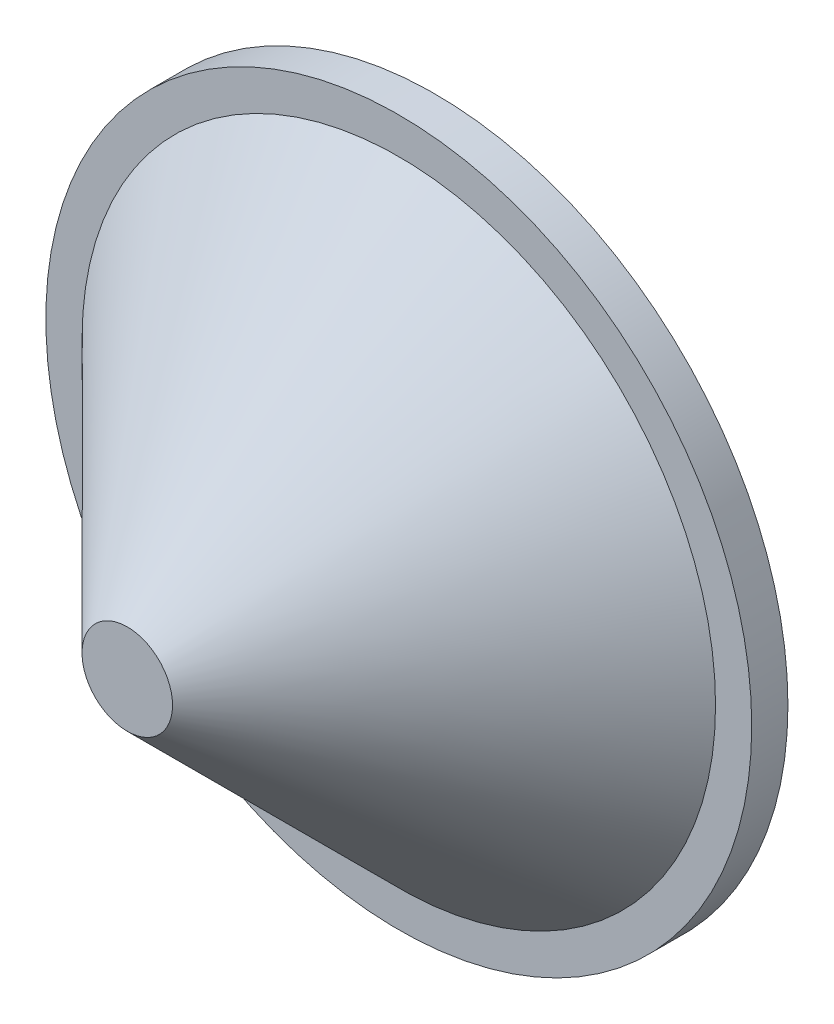
from build123d import *

# Parameters (mm, degrees)
EXTRUDE_1_DEPTH = 5


with BuildPart() as part:
    # Эскиз1 → Повернуть1 (revolve)
    with BuildSketch(Plane(origin=(0, 0, 0), x_dir=(0, 0, -1), z_dir=(1, 0, 0))):
        Polygon((0, 0), (0, 39), (-4, 39), (-4, 35), (-34, 5), (-34, 0), align=None)
    revolve(axis=Axis((0, 0, 926.802095793), (0, 0, -1)))

    # Эскиз2 → Бобышка-Вытянуть1 (add)
    with BuildSketch(Plane(origin=(0, 0, 0), x_dir=(-1, 0, 0), z_dir=(0, 0, -1))):
        Polygon((12.5, -15.5), (-12.5, -15.5), (-15.5, -12.5), (-15.5, 12.5), (-12.5, 15.5), (12.5, 15.5), (15.5, 12.5), (15.5, -12.5), align=None)
    extrude(amount=EXTRUDE_1_DEPTH)


solid = part.part
